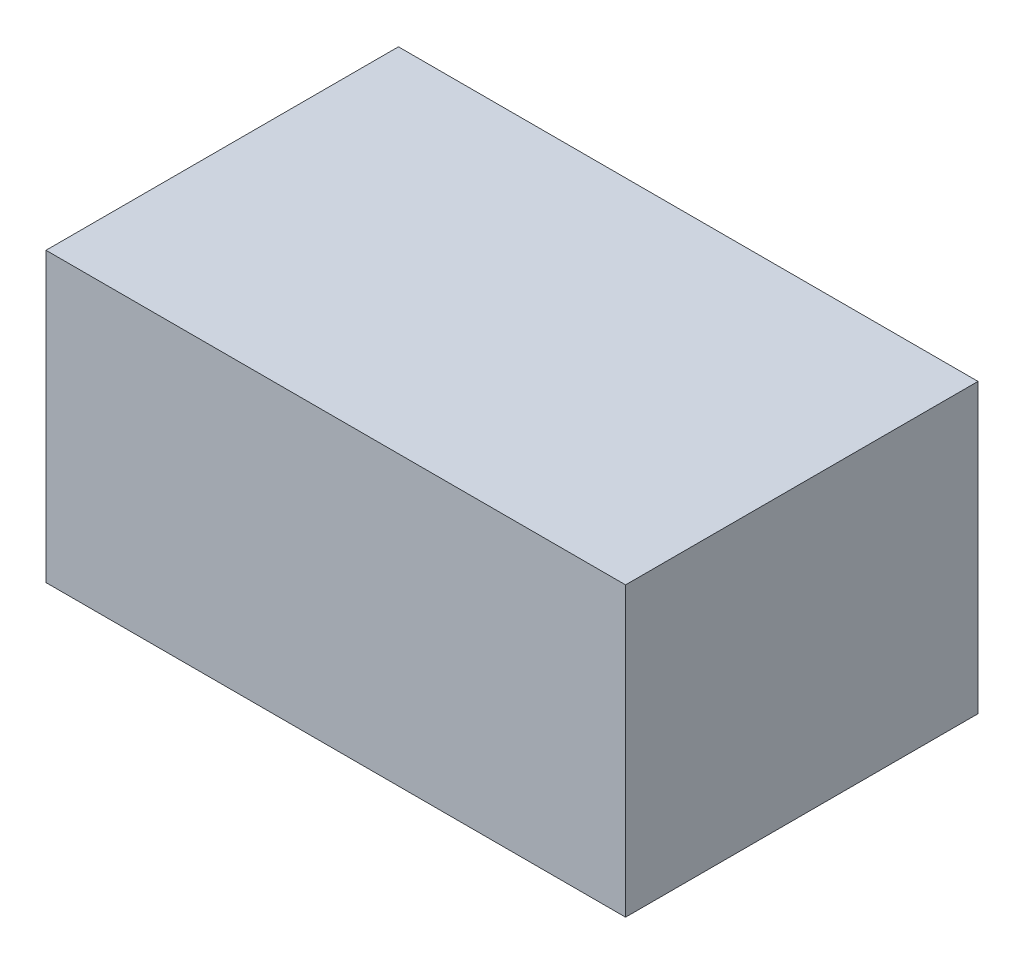
from build123d import *

# Parameters (mm, degrees)
SKETCH1_W  = 14.8
SKETCH1_H  = 7.35
MAIN_DEPTH = 9


with BuildPart() as part:
    # Sketch1 → Main (new body)
    with BuildSketch(Plane.XY):
        with Locations((7.4, 3.675)):
            Rectangle(SKETCH1_W, SKETCH1_H)
    extrude(amount=MAIN_DEPTH)


solid = part.part
